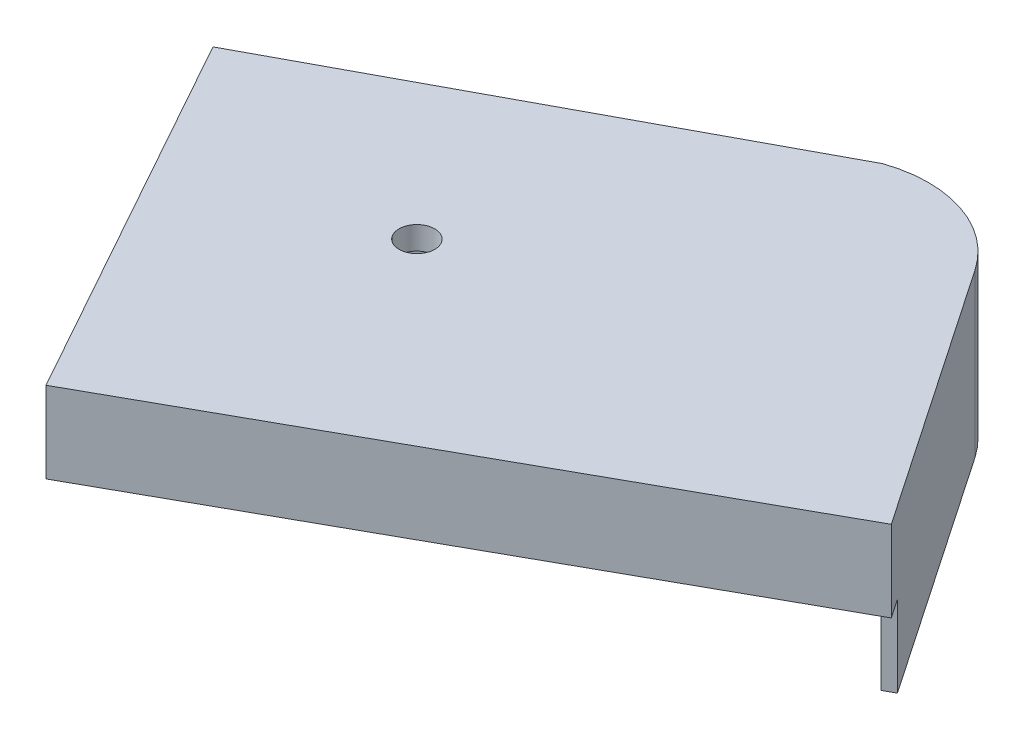
from build123d import *

# Parameters (mm, degrees)
BOSS_EXTRUDE1_DEPTH = 35.814
CUT_EXTRUDE1_DEPTH  = 30.734
SKETCH5_R           = 3.937
CUT_EXTRUDE2_DEPTH  = 12.7
SKETCH7_W           = 137.16
SKETCH7_H           = 17.907
CUT_EXTRUDE3_DEPTH  = 5.08
SKETCH8_W           = 90.016933803
SKETCH8_H           = 17.907
CUT_EXTRUDE4_DEPTH  = 5.08


with BuildPart() as part:
    # Sketch1 → Boss-Extrude1 (new body)
    with BuildSketch(Plane(origin=(0, 0, 0), x_dir=(1, 0, 0), z_dir=(0, 1, 0))):
        with BuildLine():
            Line((94.928870908, -1.703626264), (55.529419709, 56.18731626))
            ThreePointArc((55.529419709, 56.18731626), (41.967930942, 66.402029849), (24.990687805, 66.235997574))
            Line((24.990687805, 66.235997574), (-71.166136997, 14.689688471))
            Line((-71.166136997, 14.689688471), (-24.920143323, -68.405045948))
            Line((-24.920143323, -68.405045948), (94.928870908, -1.703626264))
        make_face()
    extrude(amount=BOSS_EXTRUDE1_DEPTH)

    # Sketch1_6 → Cut-Extrude1 (cut)
    with BuildSketch(Plane(origin=(0, 0, 0), x_dir=(1, 0, 0), z_dir=(0, 1, 0))):
        with BuildLine():
            Line((26.052021788, 63.812159478), (-67.558235137, 13.630976306))
            Line((-67.558235137, 13.630976306), (-23.898074198, -64.817537603))
            Line((-23.898074198, -64.817537603), (91.124715274, -0.802131195))
            Line((91.124715274, -0.802131195), (53.348830885, 54.703249855))
            ThreePointArc((53.348830885, 54.703249855), (41.23793969, 63.8651945), (26.052021788, 63.812159478))
        make_face()
    extrude(amount=CUT_EXTRUDE1_DEPTH, mode=Mode.SUBTRACT)

    # Sketch5 → Cut-Extrude2 (cut)
    with BuildSketch(Plane(origin=(0, 35.814, 0), x_dir=(1, 0, 0), z_dir=(0, 1, 0))):
        with Locations((-11.924156141, 0.45361366)):
            Circle(SKETCH5_R)
    extrude(amount=-CUT_EXTRUDE2_DEPTH, mode=Mode.SUBTRACT)

    # Sketch7 → Cut-Extrude3 (cut)
    with BuildSketch(Plane(origin=(23.173771068, 0, 41.638598275), x_dir=(0.8737898383745012, 0, -0.48630373055680265), z_dir=(0.48630373055680265, 0, 0.8737898383745012))):
        with Locations((13.53940296, 8.9535)):
            Rectangle(SKETCH7_W, SKETCH7_H)
    extrude(amount=-CUT_EXTRUDE3_DEPTH, mode=Mode.SUBTRACT)

    # Sketch8 → Cut-Extrude4 (cut)
    with BuildSketch(Plane(origin=(-48.093914392, 0, 26.766447673), x_dir=(0.48630373055680204, 0, 0.8737898383745015), z_dir=(-0.8737898383745015, 0, 0.4863037305568021))):
        with Locations((-2.435591524, 8.9535)):
            Rectangle(SKETCH8_W, SKETCH8_H)
    extrude(amount=-CUT_EXTRUDE4_DEPTH, mode=Mode.SUBTRACT)


solid = part.part
